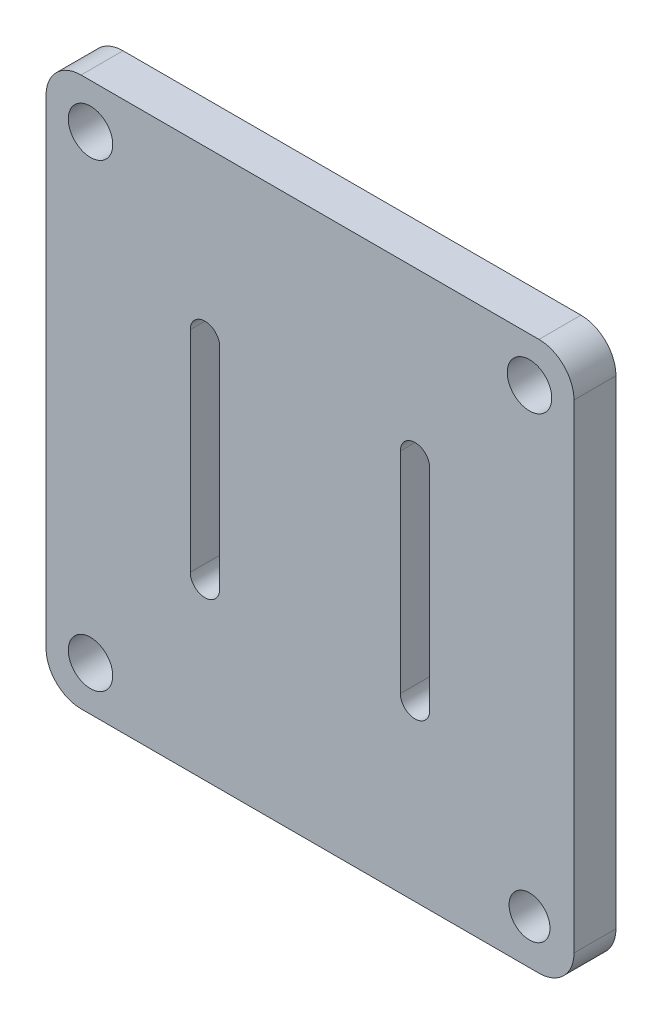
from build123d import *

# Parameters (mm, degrees)
SKETCH1_R           = 2.921
SKETCH1_R_2         = 3.175
BOSS_EXTRUDE1_DEPTH = 5.9944


with BuildPart() as part:
    # Sketch1 → Boss-Extrude1 (new body)
    with BuildSketch(Plane(origin=(0, 0, 0), x_dir=(-1, 0, 0), z_dir=(0, 0, 1))):
        with BuildLine():
            Line((566.61706408, -610.968899583), (566.61706408, -679.368899583))
            ThreePointArc((566.61706408, -679.368899583), (568.081530174, -682.904433489), (571.61706408, -684.368899583))
            Line((571.61706408, -684.368899583), (637.01706408, -684.368899583))
            ThreePointArc((637.01706408, -684.368899583), (640.552597986, -682.904433489), (642.01706408, -679.368899583))
            Line((642.01706408, -679.368899583), (642.01706408, -610.968899583))
            ThreePointArc((642.01706408, -610.968899583), (640.552597986, -607.433365677), (637.01706408, -605.968899583))
            Line((637.01706408, -605.968899583), (571.61706408, -605.968899583))
            ThreePointArc((571.61706408, -605.968899583), (568.081530174, -607.433365677), (566.61706408, -610.968899583))
        make_face()
        with Locations((572.96706408, -612.318899583)):
            Circle(SKETCH1_R, mode=Mode.SUBTRACT)
        with Locations((635.66706408, -612.318899583)):
            Circle(SKETCH1_R_2, mode=Mode.SUBTRACT)
        with Locations((635.66706408, -678.018899583)):
            Circle(SKETCH1_R_2, mode=Mode.SUBTRACT)
        with Locations((572.96706408, -678.018899583)):
            Circle(SKETCH1_R_2, mode=Mode.SUBTRACT)
        with BuildLine():
            ThreePointArc((587.220270562, -660.668899583), (589.31706408, -662.765693101), (591.413857599, -660.668899583))
            Line((591.413857599, -660.668899583), (591.413857599, -630.668899583))
            ThreePointArc((591.413857599, -630.668899583), (589.31706408, -628.572106065), (587.220270562, -630.668899583))
            Line((587.220270562, -630.668899583), (587.220270562, -660.668899583))
        make_face(mode=Mode.SUBTRACT)
        with BuildLine():
            ThreePointArc((617.214915153, -660.668899583), (619.31706408, -662.771048511), (621.419213008, -660.668899583))
            Line((621.419213008, -660.668899583), (621.419213008, -630.668899583))
            ThreePointArc((621.419213008, -630.668899583), (619.31706408, -628.566750655), (617.214915153, -630.668899583))
            Line((617.214915153, -630.668899583), (617.214915153, -660.668899583))
        make_face(mode=Mode.SUBTRACT)
    extrude(amount=BOSS_EXTRUDE1_DEPTH)


solid = part.part
